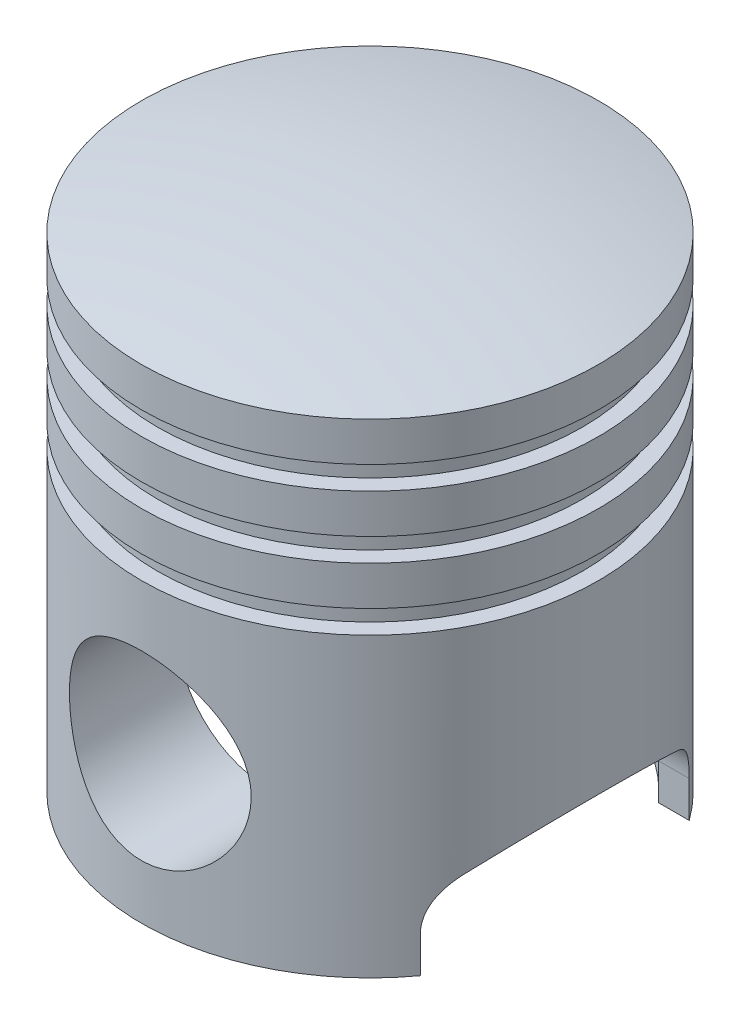
from build123d import *

# Parameters (mm, degrees)
SKETCH4_R                = 1079.5
BOSS_EXTRUDE2_DEPTH      = 2286
CUT_EXTRUDE1_START       = -185.42
SKETCH5_OUTSIDE_W        = 2923.846
SKETCH5_OUTSIDE_H        = 2923.846
SKETCH5_OUTSIDE_R        = 1003.3
CUT_EXTRUDE1_DEPTH       = 109.22
LPATTERN1_COUNT          = 3
LPATTERN1_PITCH          = 294.64
SKETCH6_R                = 965.2
CUT_EXTRUDE2_DEPTH       = 2159
DOME1_FACE_RADIUS        = 1079.5
DOME1_HEIGHT             = 127
SKETCH7_R                = 429.26
CUT_EXTRUDE3_DEPTH       = 2856.382548801
CUT_EXTRUDE3_DEPTH_BACK  = 2856.382548801
CUT_EXTRUDE4_DEPTH       = 2856.382548877
CUT_EXTRUDE4_DEPTH_BACK  = 2856.382548877
FILLET1_R                = 254
BOSS_EXTRUDE3_REACH      = 3339.983
BOSS_EXTRUDE3_END_RADIUS = 965.2
BOSS_EXTRUDE3_START      = 482.6
SKETCH9_R                = 571.5
SKETCH9_R_2              = 429.26


with BuildPart() as part:
    # Sketch4 → Boss-Extrude2 (new body)
    with BuildSketch(Plane(origin=(0, 0, 0), x_dir=(1, 0, 0), z_dir=(0, 1, 0))):
        with Locations(Location((0, 0, 0), (0, 0, 270))):
            Circle(SKETCH4_R)
    extrude(amount=BOSS_EXTRUDE2_DEPTH)

    # Sketch5 outside → Cut-Extrude1 (cut)
    with BuildSketch(Plane(origin=(0, 2286, 0), x_dir=(1, 0, 0), z_dir=(0, 1, 0)).offset(CUT_EXTRUDE1_START)):
        Rectangle(SKETCH5_OUTSIDE_W, SKETCH5_OUTSIDE_H)
        with Locations(Location((0, 0, 0), (0, 0, 270))):
            Circle(SKETCH5_OUTSIDE_R, mode=Mode.SUBTRACT)
    cut_extrude1 = extrude(amount=-CUT_EXTRUDE1_DEPTH, mode=Mode.SUBTRACT)

    # LPattern1: Cut-Extrude1 ×3
    with Locations(*[(0, -i * LPATTERN1_PITCH, 0) for i in range(1, LPATTERN1_COUNT)]):
        add(cut_extrude1, mode=Mode.SUBTRACT)

    # Sketch6 → Cut-Extrude2 (cut)
    with BuildSketch(Plane.XZ):
        with Locations(Location((0, 0, 0), (0, 0, 270))):
            Circle(SKETCH6_R)
    extrude(amount=-CUT_EXTRUDE2_DEPTH, mode=Mode.SUBTRACT)

    # Dome1: a dome of height H over a round flat face of radius A is a cap of a sphere of radius (A * A + H * H) / (2 * H)
    dome1_r = (DOME1_FACE_RADIUS * DOME1_FACE_RADIUS + DOME1_HEIGHT * DOME1_HEIGHT) / (2 * DOME1_HEIGHT)
    dome1_base = Plane((0, 2286, 0), z_dir=(0, 1, 0))
    with Locations(dome1_base.offset(DOME1_HEIGHT - dome1_r)):
        dome1_ball = Sphere(dome1_r, mode=Mode.PRIVATE)
    add(split(dome1_ball, bisect_by=dome1_base, keep=Keep.TOP, mode=Mode.PRIVATE))

    # Sketch7 → Cut-Extrude3 (cut, two sides)
    with BuildSketch(Plane.XY) as cut_extrude3_sk:
        with Locations((0, 685.8)):
            Circle(SKETCH7_R)
    extrude(amount=CUT_EXTRUDE3_DEPTH, mode=Mode.SUBTRACT)
    extrude(cut_extrude3_sk.sketch, amount=-CUT_EXTRUDE3_DEPTH_BACK, mode=Mode.SUBTRACT)

    # Sketch8 → Cut-Extrude4 (cut, two sides)
    with BuildSketch(Plane(origin=(0, 0, 0), x_dir=(0, 0, -1), z_dir=(1, 0, 0))) as cut_extrude4_sk:
        with BuildLine():
            Line((-635, 0), (-635, 304.8))
            ThreePointArc((-635, 304.8), (0, 527.685254203), (635, 304.8))
            Line((635, 304.8), (635, 0))
            Line((635, 0), (-635, 0))
        make_face()
    extrude(amount=CUT_EXTRUDE4_DEPTH, mode=Mode.SUBTRACT)
    extrude(cut_extrude4_sk.sketch, amount=-CUT_EXTRUDE4_DEPTH_BACK, mode=Mode.SUBTRACT)

    # Fillet1
    fillet1_edges = [part.edges().sort_by_distance(p)[0] for p in [
        (-799.941170684, 304.8, 635),
        (799.941170684, 304.8, 635),
        (799.941170684, 304.8, -635),
        (-799.941170684, 304.8, -635),
    ]]
    fillet(fillet1_edges, radius=FILLET1_R)

    # Boss-Extrude3: up to this cylinder (the profile starts inside it)
    boss_extrude3_end = Plane(origin=(0, 685.8, 0), z_dir=(0, -1, 0)) * Cylinder(BOSS_EXTRUDE3_END_RADIUS, 8611.366, mode=Mode.PRIVATE)
    # Sketch9 → Boss-Extrude3 (add, up to the surface)
    with BuildSketch(Plane.XY.offset(BOSS_EXTRUDE3_START), mode=Mode.PRIVATE) as boss_extrude3_sk1:
        with Locations(Location((0, 685.8, 0), (0, 0, 180))):
            Circle(SKETCH9_R)
        with Locations((0, 685.8)):
            Circle(SKETCH9_R_2, mode=Mode.SUBTRACT)
    boss_extrude3_tool1 = extrude(boss_extrude3_sk1.sketch, amount=BOSS_EXTRUDE3_REACH, mode=Mode.PRIVATE) & boss_extrude3_end
    boss_extrude3 = boss_extrude3_tool1.solids().sort_by_distance((555.335539, 685.8, 482.6))[0]
    add(boss_extrude3)

    # Mirror1: Boss-Extrude3 across plane
    add(boss_extrude3.mirror(Plane.XY))


solid = part.part
